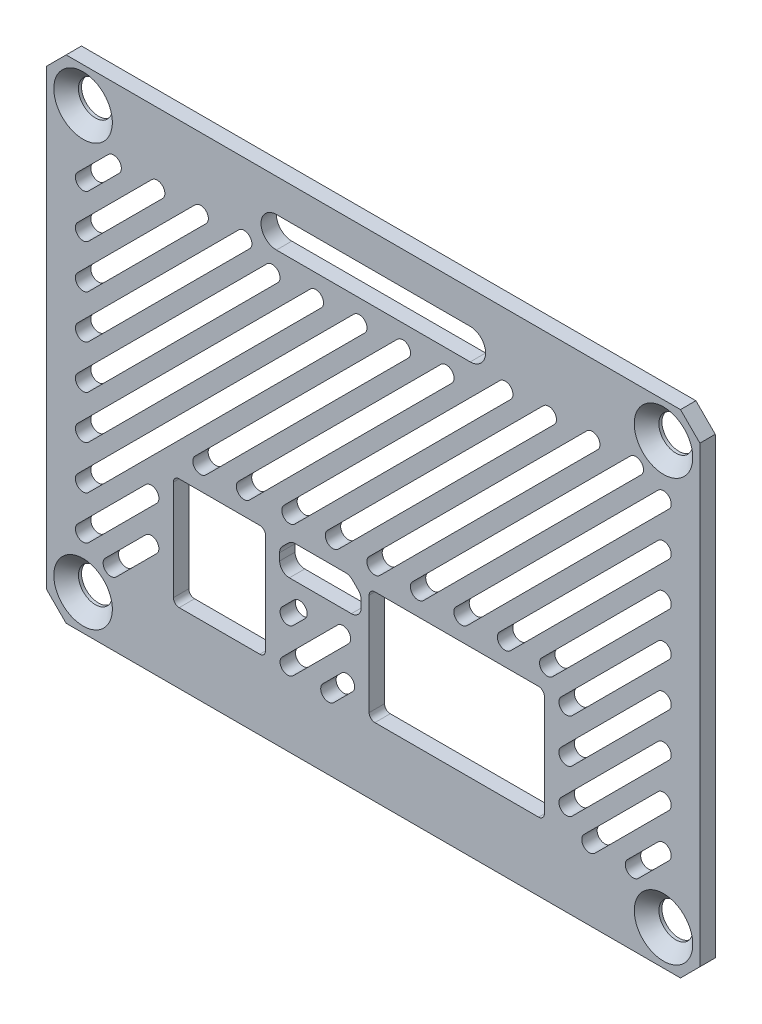
from build123d import *

# Parameters (mm, degrees)
SKETCH1_W           = 67.4
SKETCH1_H           = 50.8
BOSS_EXTRUDE1_DEPTH = 1.5875
CHAMFER1_SIZE       = 2
SKETCH3_R           = 1.75
CUT_EXTRUDE2_DEPTH  = 2.5875
CHAMFER2_SIZE       = 1.27
CUT_EXTRUDE4_DEPTH  = 2.5875
CUT_EXTRUDE1_DEPTH  = 2.5875
CUT_EXTRUDE5_DEPTH  = 2.5875


with BuildPart() as part:
    # Sketch1 → Boss-Extrude1 (new body)
    with BuildSketch(Plane.XY):
        with Locations((33.7, 25.4)):
            Rectangle(SKETCH1_W, SKETCH1_H)
    extrude(amount=BOSS_EXTRUDE1_DEPTH)

    # Chamfer1
    chamfer1_edges = [part.edges().sort_by_distance(p)[0] for p in [
        (0, 50.8, 0.79375),
        (67.4, 50.8, 0.79375),
        (67.4, 0, 0.79375),
        (0, 0, 0.79375),
    ]]
    chamfer(chamfer1_edges, length=CHAMFER1_SIZE)

    # Sketch3 → Cut-Extrude2 (cut, through all)
    with BuildSketch(Plane.XY.offset(1.5875)):
        with Locations((3.75, 47.15)):
            Circle(SKETCH3_R)
        with Locations((3.75, 3.65)):
            Circle(SKETCH3_R)
        with Locations((63.65, 3.65)):
            Circle(SKETCH3_R)
        with Locations((63.65, 47.15)):
            Circle(SKETCH3_R)
    extrude(amount=-CUT_EXTRUDE2_DEPTH, mode=Mode.SUBTRACT)

    # Chamfer2
    chamfer2_edges = [part.edges().sort_by_distance(p)[0] for p in [
        (2, 47.15, 1.5875),
        (2, 3.65, 1.5875),
        (61.9, 3.65, 1.5875),
        (61.9, 47.15, 1.5875),
    ]]
    chamfer(chamfer2_edges, length=CHAMFER2_SIZE)

    # Sketch5 → Cut-Extrude4 (cut, through all)
    with BuildSketch(Plane.XY.offset(1.5875)):
        with BuildLine():
            Line((23.7, 47.3875), (43.7, 47.3875))
            ThreePointArc((43.7, 47.3875), (45.2875, 45.8), (43.7, 44.2125))
            Line((43.7, 44.2125), (23.7, 44.2125))
            ThreePointArc((23.7, 44.2125), (22.1125, 45.8), (23.7, 47.3875))
        make_face()
    extrude(amount=-CUT_EXTRUDE4_DEPTH, mode=Mode.SUBTRACT)

    # Sketch2 → Cut-Extrude1 (cut, through all)
    with BuildSketch(Plane.XY.offset(1.5875)):
        with BuildLine():
            Line((50.7576875, 7.0575), (33.8635125, 7.0575))
            ThreePointArc((33.8635125, 7.0575), (33.442562994, 7.231862994), (33.2682, 7.6528125))
            Line((33.2682, 7.6528125), (33.2682, 18.1461875))
            ThreePointArc((33.2682, 18.1461875), (33.442562994, 18.567137006), (33.8635125, 18.7415))
            Line((33.8635125, 18.7415), (50.7576875, 18.7415))
            ThreePointArc((50.7576875, 18.7415), (51.178637006, 18.567137006), (51.353, 18.1461875))
            Line((51.353, 18.1461875), (51.353, 7.6528125))
            ThreePointArc((51.353, 7.6528125), (51.178637006, 7.231862994), (50.7576875, 7.0575))
        make_face()
        with BuildLine():
            Line((21.9838055, 7.2335), (13.6664305, 7.2335))
            ThreePointArc((13.6664305, 7.2335), (13.245480994, 7.407862994), (13.071118, 7.8288125))
            Line((13.071118, 7.8288125), (13.071118, 18.1461875))
            ThreePointArc((13.071118, 18.1461875), (13.245480994, 18.567137006), (13.6664305, 18.7415))
            Line((13.6664305, 18.7415), (21.9838055, 18.7415))
            ThreePointArc((21.9838055, 18.7415), (22.404755006, 18.567137006), (22.579118, 18.1461875))
            Line((22.579118, 18.1461875), (22.579118, 7.8288125))
            ThreePointArc((22.579118, 7.8288125), (22.404755006, 7.407862994), (21.9838055, 7.2335))
        make_face()
        with BuildLine():
            Line((24.034944, 17.333946609), (24.034944, 16.5875))
            ThreePointArc((24.034944, 16.5875), (24.329008792, 15.877564792), (25.038944, 15.5835))
            Line((25.038944, 15.5835), (31.438944, 15.5835))
            ThreePointArc((31.438944, 15.5835), (32.148879208, 15.877564792), (32.442944, 16.5875))
            Line((32.442944, 16.5875), (32.442944, 17.333946609))
            ThreePointArc((32.442944, 17.333946609), (32.366519051, 17.718160776), (32.148879208, 18.043881818))
            Line((32.148879208, 18.043881818), (31.545325818, 18.647435208))
            ThreePointArc((31.545325818, 18.647435208), (31.219604776, 18.865075051), (30.835390609, 18.9415))
            Line((30.835390609, 18.9415), (25.642497391, 18.9415))
            ThreePointArc((25.642497391, 18.9415), (25.258283224, 18.865075051), (24.932562182, 18.647435208))
            Line((24.932562182, 18.647435208), (24.329008792, 18.043881818))
            ThreePointArc((24.329008792, 18.043881818), (24.111368949, 17.718160776), (24.034944, 17.333946609))
        make_face()
    extrude(amount=-CUT_EXTRUDE1_DEPTH, mode=Mode.SUBTRACT)

    # Sketch6 → Cut-Extrude5 (cut, through all)
    with BuildSketch(Plane.XY.offset(1.5875)):
        with BuildLine():
            Line((64.211266008, 9.887453387), (61.056296613, 6.732483992))
            ThreePointArc((61.056296613, 6.732483992), (59.933764598, 6.732483992), (59.933764598, 7.855016008))
            Line((59.933764598, 7.855016008), (63.088733992, 11.009985402))
            ThreePointArc((63.088733992, 11.009985402), (64.211266008, 11.009985402), (64.211266008, 9.887453387))
        make_face()
        with BuildLine():
            Line((64.211266008, 14.377581448), (56.566168552, 6.732483992))
            ThreePointArc((56.566168552, 6.732483992), (55.443636537, 6.732483992), (55.443636537, 7.855016008))
            Line((55.443636537, 7.855016008), (63.088733992, 15.500113463))
            ThreePointArc((63.088733992, 15.500113463), (64.211266008, 15.500113463), (64.211266008, 14.377581448))
        make_face()
        with BuildLine():
            Line((64.211266008, 18.867709508), (54.208016008, 8.864459508))
            ThreePointArc((54.208016008, 8.864459508), (53.085483992, 8.864459508), (53.085483992, 9.986991523))
            Line((53.085483992, 9.986991523), (63.088733992, 19.990241523))
            ThreePointArc((63.088733992, 19.990241523), (64.211266008, 19.990241523), (64.211266008, 18.867709508))
        make_face()
        with BuildLine():
            Line((64.211266008, 23.357837569), (54.208016008, 13.354587569))
            ThreePointArc((54.208016008, 13.354587569), (53.085483992, 13.354587569), (53.085483992, 14.477119584))
            Line((53.085483992, 14.477119584), (63.088733992, 24.480369584))
            ThreePointArc((63.088733992, 24.480369584), (64.211266008, 24.480369584), (64.211266008, 23.357837569))
        make_face()
        with BuildLine():
            Line((64.211266008, 27.847965629), (54.208016008, 17.844715629))
            ThreePointArc((54.208016008, 17.844715629), (53.085483992, 17.844715629), (53.085483992, 18.967247644))
            Line((53.085483992, 18.967247644), (63.088733992, 28.970497644))
            ThreePointArc((63.088733992, 28.970497644), (64.211266008, 28.970497644), (64.211266008, 27.847965629))
        make_face()
        with BuildLine():
            Line((7.466235402, 42.944983992), (4.311266008, 39.790014598))
            ThreePointArc((4.311266008, 39.790014598), (3.188733992, 39.790014598), (3.188733992, 40.912546613))
            Line((3.188733992, 40.912546613), (6.343703387, 44.067516008))
            ThreePointArc((6.343703387, 44.067516008), (7.466235402, 44.067516008), (7.466235402, 42.944983992))
        make_face()
        with BuildLine():
            Line((64.211266008, 32.33809369), (52.207215871, 20.334043553))
            ThreePointArc((52.207215871, 20.334043553), (51.084683856, 20.334043553), (51.084683856, 21.456575568))
            Line((51.084683856, 21.456575568), (63.088733992, 33.460625705))
            ThreePointArc((63.088733992, 33.460625705), (64.211266008, 33.460625705), (64.211266008, 32.33809369))
        make_face()
        with BuildLine():
            Line((64.211266008, 36.82822175), (47.85702825, 20.473983992))
            ThreePointArc((47.85702825, 20.473983992), (46.734496235, 20.473983992), (46.734496235, 21.596516008))
            Line((46.734496235, 21.596516008), (63.088733992, 37.950753765))
            ThreePointArc((63.088733992, 37.950753765), (64.211266008, 37.950753765), (64.211266008, 36.82822175))
        make_face()
        with BuildLine():
            Line((64.211266008, 41.318349811), (43.366900189, 20.473983992))
            ThreePointArc((43.366900189, 20.473983992), (42.244368174, 20.473983992), (42.244368174, 21.596516008))
            Line((42.244368174, 21.596516008), (63.088733992, 42.440881826))
            ThreePointArc((63.088733992, 42.440881826), (64.211266008, 42.440881826), (64.211266008, 41.318349811))
        make_face()
        with BuildLine():
            Line((61.347772129, 42.944983992), (38.876772129, 20.473983992))
            ThreePointArc((38.876772129, 20.473983992), (37.754240114, 20.473983992), (37.754240114, 21.596516008))
            Line((37.754240114, 21.596516008), (60.225240114, 44.067516008))
            ThreePointArc((60.225240114, 44.067516008), (61.347772129, 44.067516008), (61.347772129, 42.944983992))
        make_face()
        with BuildLine():
            Line((26.641144068, 12.728483992), (25.434134008, 11.521473932))
            ThreePointArc((25.434134008, 11.521473932), (24.311601992, 11.521473932), (24.311601992, 12.644005947))
            Line((24.311601992, 12.644005947), (25.518612053, 13.851016008))
            ThreePointArc((25.518612053, 13.851016008), (26.641144068, 13.851016008), (26.641144068, 12.728483992))
        make_face()
        with BuildLine():
            Line((56.857644068, 42.944983992), (34.386644068, 20.473983992))
            ThreePointArc((34.386644068, 20.473983992), (33.264112053, 20.473983992), (33.264112053, 21.596516008))
            Line((33.264112053, 21.596516008), (55.735112053, 44.067516008))
            ThreePointArc((55.735112053, 44.067516008), (56.857644068, 44.067516008), (56.857644068, 42.944983992))
        make_face()
        with BuildLine():
            Line((52.367516008, 42.944983992), (30.096516008, 20.673983992))
            ThreePointArc((30.096516008, 20.673983992), (28.973983992, 20.673983992), (28.973983992, 21.796516008))
            Line((28.973983992, 21.796516008), (51.244983992, 44.067516008))
            ThreePointArc((51.244983992, 44.067516008), (52.367516008, 44.067516008), (52.367516008, 42.944983992))
        make_face()
        with BuildLine():
            Line((47.877387947, 42.944983992), (25.606387947, 20.673983992))
            ThreePointArc((25.606387947, 20.673983992), (24.483855932, 20.673983992), (24.483855932, 21.796516008))
            Line((24.483855932, 21.796516008), (46.754855932, 44.067516008))
            ThreePointArc((46.754855932, 44.067516008), (47.877387947, 44.067516008), (47.877387947, 42.944983992))
        make_face()
        with BuildLine():
            Line((41.799759886, 41.357483992), (20.916259886, 20.473983992))
            ThreePointArc((20.916259886, 20.473983992), (19.793727871, 20.473983992), (19.793727871, 21.596516008))
            Line((19.793727871, 21.596516008), (40.677227871, 42.480016008))
            ThreePointArc((40.677227871, 42.480016008), (41.799759886, 42.480016008), (41.799759886, 41.357483992))
        make_face()
        with BuildLine():
            Line((37.309631826, 41.357483992), (16.426131826, 20.473983992))
            ThreePointArc((16.426131826, 20.473983992), (15.303599811, 20.473983992), (15.303599811, 21.596516008))
            Line((15.303599811, 21.596516008), (36.187099811, 42.480016008))
            ThreePointArc((36.187099811, 42.480016008), (37.309631826, 42.480016008), (37.309631826, 41.357483992))
        make_face()
        with BuildLine():
            Line((32.819503765, 41.357483992), (4.311266008, 12.849246235))
            ThreePointArc((4.311266008, 12.849246235), (3.188733992, 12.849246235), (3.188733992, 13.97177825))
            Line((3.188733992, 13.97177825), (31.69697175, 42.480016008))
            ThreePointArc((31.69697175, 42.480016008), (32.819503765, 42.480016008), (32.819503765, 41.357483992))
        make_face()
        with BuildLine():
            Line((31.131272129, 12.728483992), (25.434134008, 7.031345871))
            ThreePointArc((25.434134008, 7.031345871), (24.311601992, 7.031345871), (24.311601992, 8.153877886))
            Line((24.311601992, 8.153877886), (30.008740114, 13.851016008))
            ThreePointArc((30.008740114, 13.851016008), (31.131272129, 13.851016008), (31.131272129, 12.728483992))
        make_face()
        with BuildLine():
            Line((28.329375705, 41.357483992), (4.311266008, 17.339374295))
            ThreePointArc((4.311266008, 17.339374295), (3.188733992, 17.339374295), (3.188733992, 18.46190631))
            Line((3.188733992, 18.46190631), (27.20684369, 42.480016008))
            ThreePointArc((27.20684369, 42.480016008), (28.329375705, 42.480016008), (28.329375705, 41.357483992))
        make_face()
        with BuildLine():
            Line((23.839247644, 41.357483992), (4.311266008, 21.829502356))
            ThreePointArc((4.311266008, 21.829502356), (3.188733992, 21.829502356), (3.188733992, 22.952034371))
            Line((3.188733992, 22.952034371), (22.716715629, 42.480016008))
            ThreePointArc((22.716715629, 42.480016008), (23.839247644, 42.480016008), (23.839247644, 41.357483992))
        make_face()
        with BuildLine():
            Line((20.936619584, 42.944983992), (4.311266008, 26.319630416))
            ThreePointArc((4.311266008, 26.319630416), (3.188733992, 26.319630416), (3.188733992, 27.442162431))
            Line((3.188733992, 27.442162431), (19.814087569, 44.067516008))
            ThreePointArc((19.814087569, 44.067516008), (20.936619584, 44.067516008), (20.936619584, 42.944983992))
        make_face()
        with BuildLine():
            Line((16.446491523, 42.944983992), (4.311266008, 30.809758477))
            ThreePointArc((4.311266008, 30.809758477), (3.188733992, 30.809758477), (3.188733992, 31.932290492))
            Line((3.188733992, 31.932290492), (15.323959508, 44.067516008))
            ThreePointArc((15.323959508, 44.067516008), (16.446491523, 44.067516008), (16.446491523, 42.944983992))
        make_face()
        with BuildLine():
            Line((11.956363463, 42.944983992), (4.311266008, 35.299886537))
            ThreePointArc((4.311266008, 35.299886537), (3.188733992, 35.299886537), (3.188733992, 36.422418552))
            Line((3.188733992, 36.422418552), (10.833831448, 44.067516008))
            ThreePointArc((10.833831448, 44.067516008), (11.956363463, 44.067516008), (11.956363463, 42.944983992))
        make_face()
        with BuildLine():
            Line((31.535716008, 8.642799811), (29.625400189, 6.732483992))
            ThreePointArc((29.625400189, 6.732483992), (28.502868174, 6.732483992), (28.502868174, 7.855016008))
            Line((28.502868174, 7.855016008), (30.413183992, 9.765331826))
            ThreePointArc((30.413183992, 9.765331826), (31.535716008, 9.765331826), (31.535716008, 8.642799811))
        make_face()
        with BuildLine():
            Line((11.338634008, 15.386486174), (4.311266008, 8.359118174))
            ThreePointArc((4.311266008, 8.359118174), (3.188733992, 8.359118174), (3.188733992, 9.481650189))
            Line((3.188733992, 9.481650189), (10.216101992, 16.509018189))
            ThreePointArc((10.216101992, 16.509018189), (11.338634008, 16.509018189), (11.338634008, 15.386486174))
        make_face()
        with BuildLine():
            Line((11.338634008, 10.896358114), (7.174759886, 6.732483992))
            ThreePointArc((7.174759886, 6.732483992), (6.052227871, 6.732483992), (6.052227871, 7.855016008))
            Line((6.052227871, 7.855016008), (10.216101992, 12.018890129))
            ThreePointArc((10.216101992, 12.018890129), (11.338634008, 12.018890129), (11.338634008, 10.896358114))
        make_face()
    extrude(amount=-CUT_EXTRUDE5_DEPTH, mode=Mode.SUBTRACT)


solid = part.part
